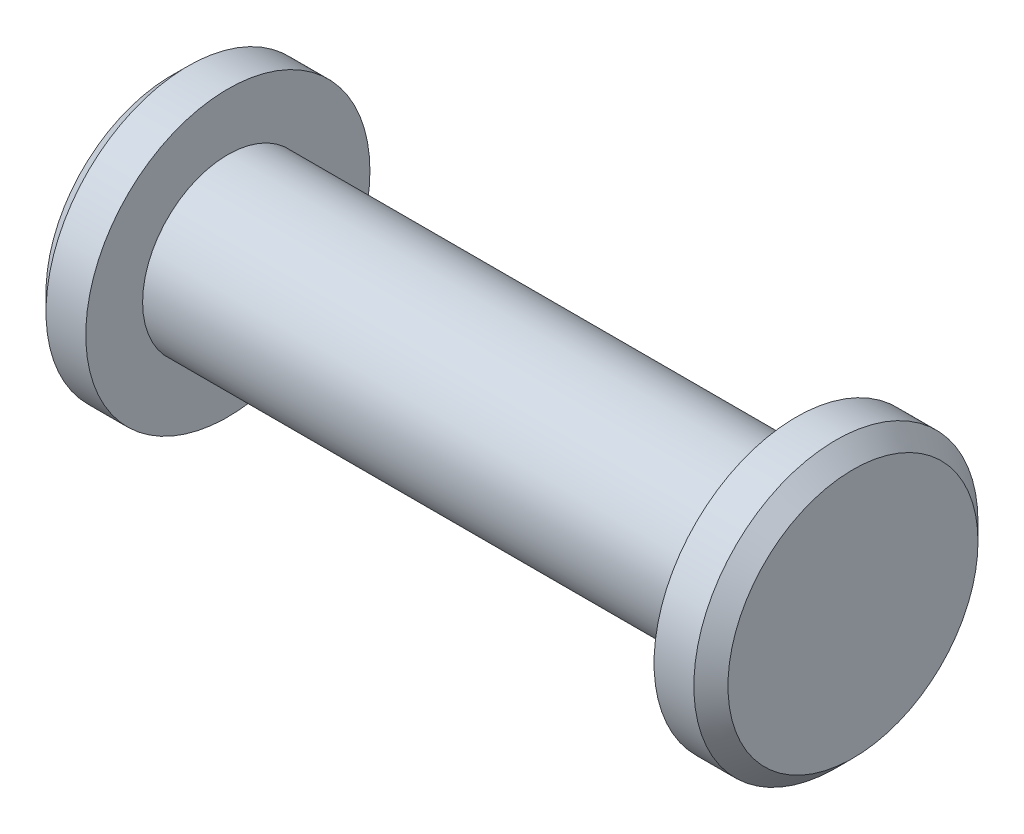
from build123d import *


with BuildPart() as part:
    # Sketch1 → Revolve1 (revolve)
    with BuildSketch(Plane.XY):
        Polygon((-50, 15), (50, 15), (50, 25), (57, 25), (60, 22), (60, 0), (-60, 0), (-60, 22), (-57, 25), (-50, 25), align=None)
    revolve(axis=Axis((60, 0, 0), (-1, 0, 0)))


solid = part.part
